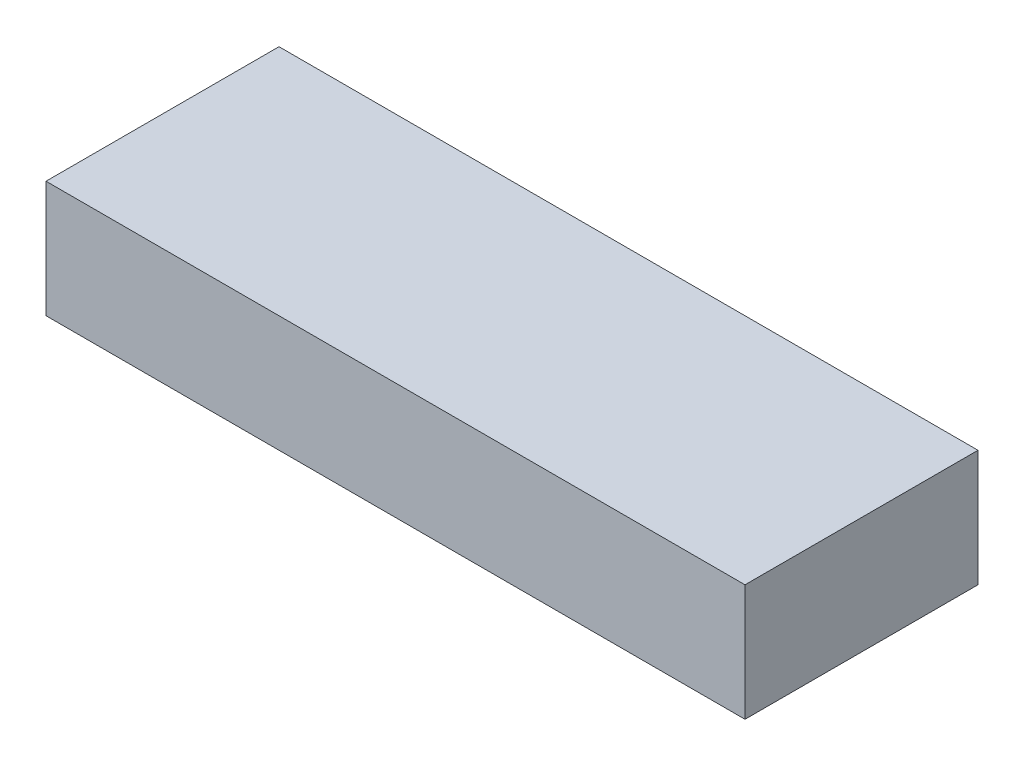
from build123d import *

# Parameters (mm, degrees)
SKETCH1_W           = 30
SKETCH1_H           = 10
BOSS_EXTRUDE1_DEPTH = 2.5


with BuildPart() as part:
    # Sketch1 → Boss-Extrude1 (new body, symmetric)
    with BuildSketch(Plane(origin=(0, 0, 0), x_dir=(1, 0, 0), z_dir=(0, 1, 0))):
        Rectangle(SKETCH1_W, SKETCH1_H)
    extrude(amount=BOSS_EXTRUDE1_DEPTH, both=True)


solid = part.part
